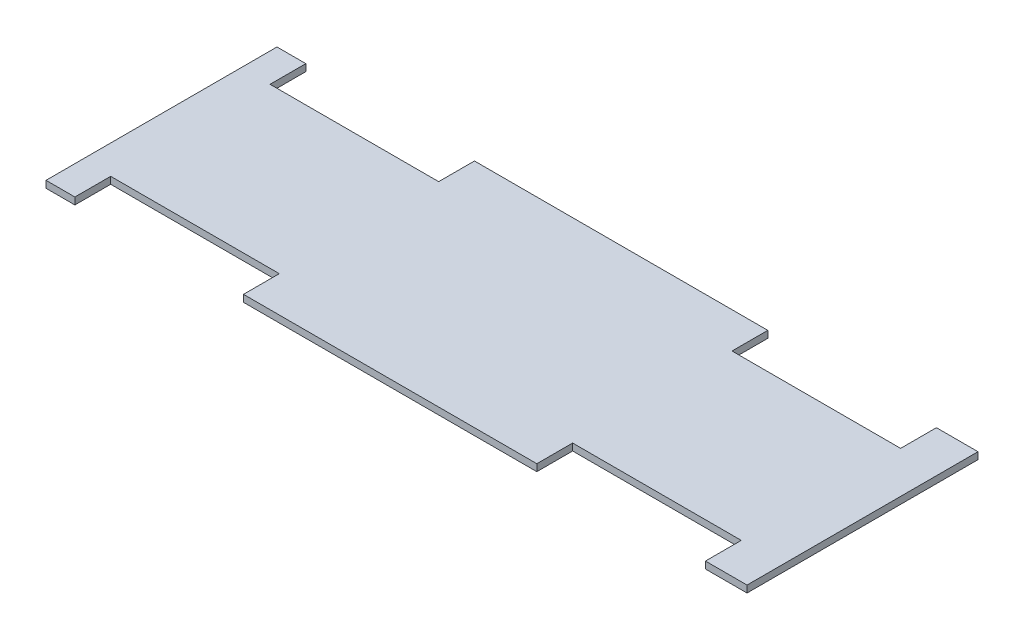
from build123d import *

# Parameters (mm, degrees)
BOSS_EXTRUDE1_DEPTH = 3


with BuildPart() as part:
    # Sketch1 → Boss-Extrude1 (new body)
    with BuildSketch(Plane(origin=(0, 0, 0), x_dir=(1, 0, 0), z_dir=(0, 1, 0))):
        Polygon((-149, -50), (-149, 50), (-136.5, 50), (-136.5, 34.5), (-63.5, 34.5), (-63.5, 50), (63.5, 50), (63.5, 34.5), (136.5, 34.5), (136.5, 50), (154.5, 50), (154.5, -50), (136.5, -50), (136.5, -34.5), (63.5, -34.5), (63.5, -50), (-63.5, -50), (-63.5, -34.5), (-136.5, -34.5), (-136.5, -50), align=None)
    extrude(amount=BOSS_EXTRUDE1_DEPTH)


solid = part.part
